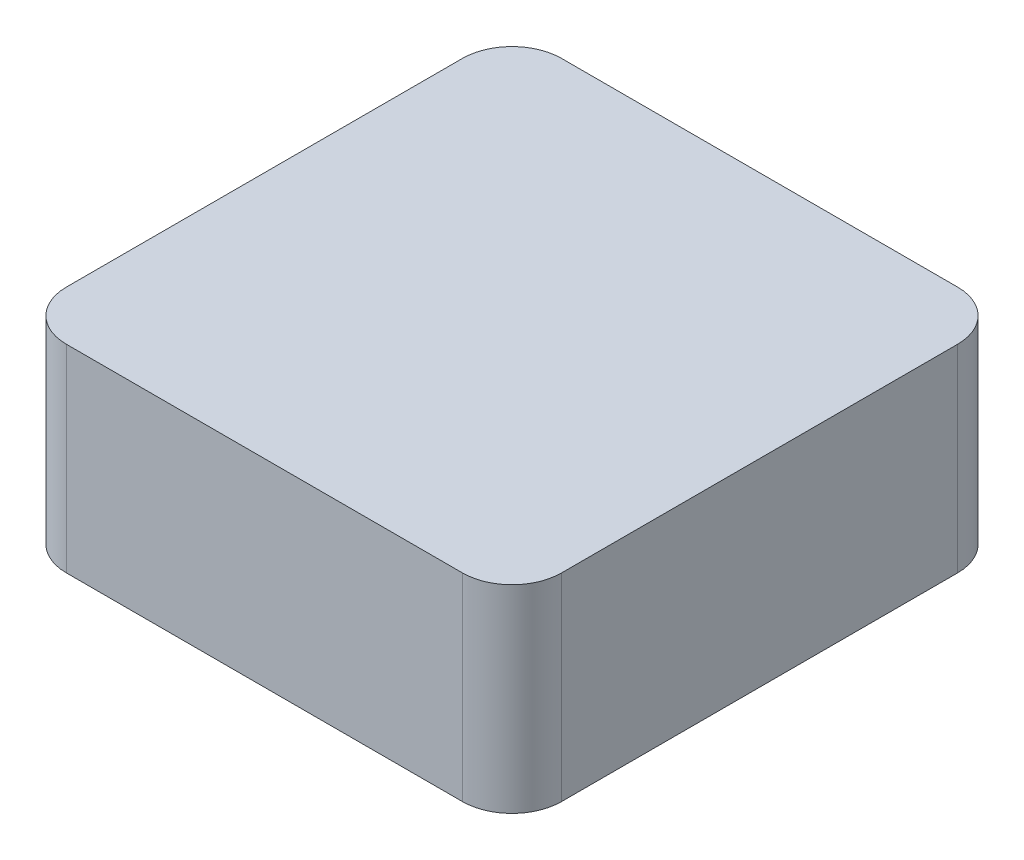
from build123d import *

# Parameters (mm, degrees)
SKETCH1_W           = 0.5
SKETCH1_H           = 0.5
BOSS_EXTRUDE1_DEPTH = 0.2
FILLET3_R           = 0.05


with BuildPart() as part:
    # Sketch1 → Boss-Extrude1 (new body)
    with BuildSketch(Plane(origin=(0, 0, 0), x_dir=(1, 0, 0), z_dir=(0, 1, 0))):
        with Locations((0.25, -0.25)):
            Rectangle(SKETCH1_W, SKETCH1_H)
    extrude(amount=BOSS_EXTRUDE1_DEPTH)

    # Fillet3
    fillet3_edges = [part.edges().sort_by_distance(p)[0] for p in [
        (0, 0.1, 0),
        (0.5, 0.1, 0),
        (0.5, 0.1, 0.5),
        (0, 0.1, 0.5),
    ]]
    fillet(fillet3_edges, radius=FILLET3_R)


solid = part.part
